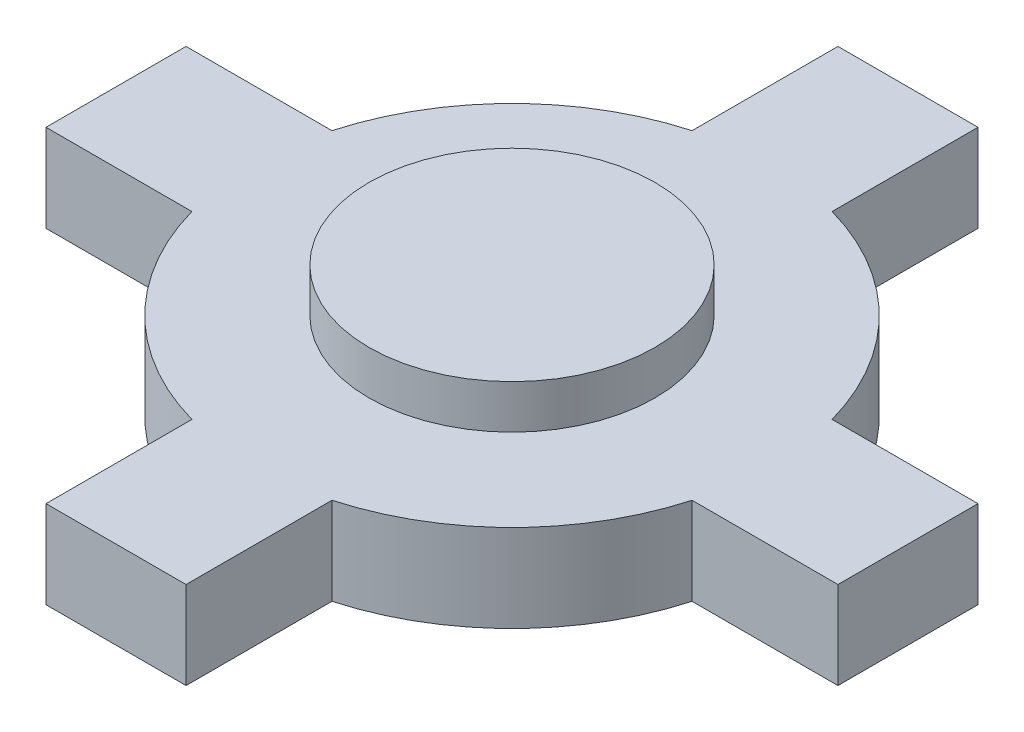
from build123d import *

# Parameters (mm, degrees)
EXTRUDE_1_DEPTH = 3
SKETCH_2_R      = 4.9
EXTRUDE_2_DEPTH = 1.5


with BuildPart() as part:
    # 草图1 → 凸台-拉伸1 (new body)
    with BuildSketch(Plane(origin=(0, 0, 0), x_dir=(1, 0, 0), z_dir=(0, 1, 0))):
        with BuildLine():
            Line((-13.570297544, 2.4), (-8.570297544, 2.4))
            ThreePointArc((-8.570297544, 2.4), (-6.293250353, 6.293250353), (-2.4, 8.570297544))
            Line((-2.4, 8.570297544), (-2.4, 13.570297544))
            Line((-2.4, 13.570297544), (2.4, 13.570297544))
            Line((2.4, 13.570297544), (2.4, 8.570297544))
            ThreePointArc((2.4, 8.570297544), (6.293250353, 6.293250353), (8.570297544, 2.4))
            Line((8.570297544, 2.4), (13.570297544, 2.4))
            Line((13.570297544, 2.4), (13.570297544, -2.4))
            Line((13.570297544, -2.4), (8.570297544, -2.4))
            ThreePointArc((8.570297544, -2.4), (6.293250353, -6.293250353), (2.4, -8.570297544))
            Line((2.4, -8.570297544), (2.4, -13.570297544))
            Line((2.4, -13.570297544), (-2.4, -13.570297544))
            Line((-2.4, -13.570297544), (-2.4, -8.570297544))
            ThreePointArc((-2.4, -8.570297544), (-6.293250353, -6.293250353), (-8.570297544, -2.4))
            Line((-8.570297544, -2.4), (-13.570297544, -2.4))
            Line((-13.570297544, -2.4), (-13.570297544, 2.4))
        make_face()
    extrude(amount=EXTRUDE_1_DEPTH)

    # 草图2 → 凸台-拉伸2 (add)
    with BuildSketch(Plane(origin=(0, 3, 0), x_dir=(1, 0, 0), z_dir=(0, 1, 0))):
        Circle(SKETCH_2_R)
    extrude(amount=EXTRUDE_2_DEPTH)


solid = part.part
